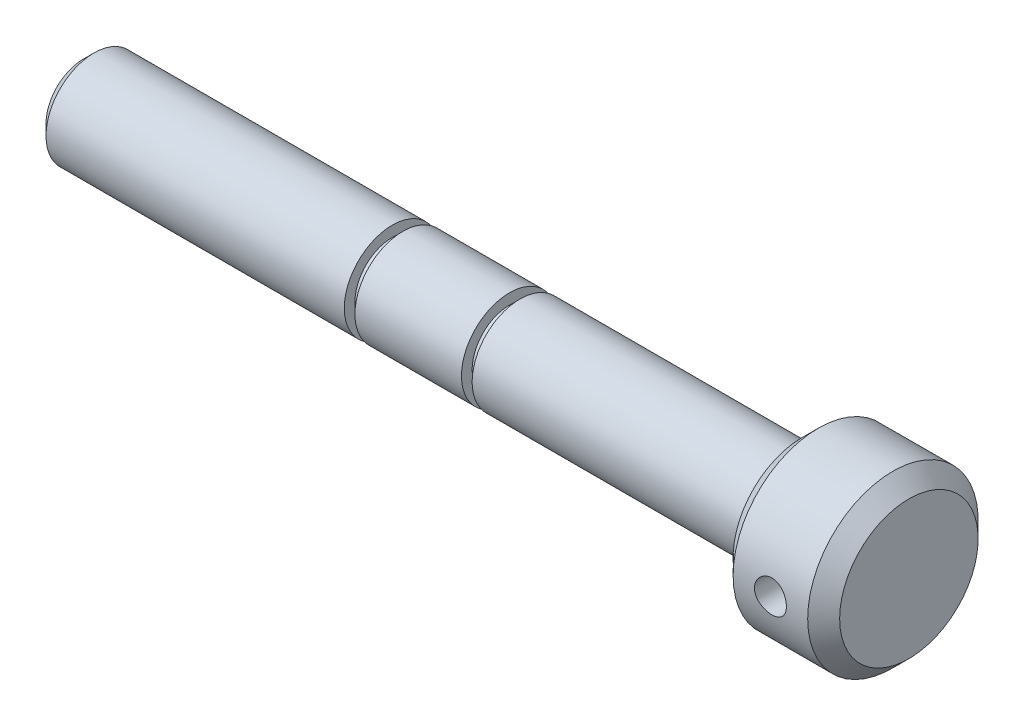
from build123d import *

# Parameters (mm, degrees)
CHAMFER1_SIZE           = 3
CHAMFER2_SIZE           = 2
SKETCH2_R               = 3
CUT_EXTRUDE1_DEPTH      = 17
CUT_EXTRUDE1_DEPTH_BACK = 17


with BuildPart() as part:
    # Sketch1 → Revolve1 (revolve)
    with BuildSketch(Plane.XY):
        Polygon((155, 0), (155, 16), (135, 16), (135, 9), (82, 9), (82, 7), (80, 7), (80, 9), (60, 9), (60, 7), (58, 7), (58, 9), (0, 9), (0, 0), align=None)
    revolve(axis=Axis((0, 0, 0), (1, 0, 0)))

    # Chamfer1
    chamfer1_edges = [part.edges().sort_by_distance(p)[0] for p in [
        (135, -16, 0),
        (155, -16, 0),
    ]]
    chamfer(chamfer1_edges, length=CHAMFER1_SIZE)

    # Chamfer2
    chamfer2_edges = [part.edges().sort_by_distance(p)[0] for p in [
        (0, -9, 0),
    ]]
    chamfer(chamfer2_edges, length=CHAMFER2_SIZE)

    # Sketch2 → Cut-Extrude1 (cut, two sides)
    with BuildSketch(Plane.XY) as cut_extrude1_sk:
        with Locations((145, 0)):
            Circle(SKETCH2_R)
    extrude(amount=CUT_EXTRUDE1_DEPTH, mode=Mode.SUBTRACT)
    extrude(cut_extrude1_sk.sketch, amount=-CUT_EXTRUDE1_DEPTH_BACK, mode=Mode.SUBTRACT)


solid = part.part
